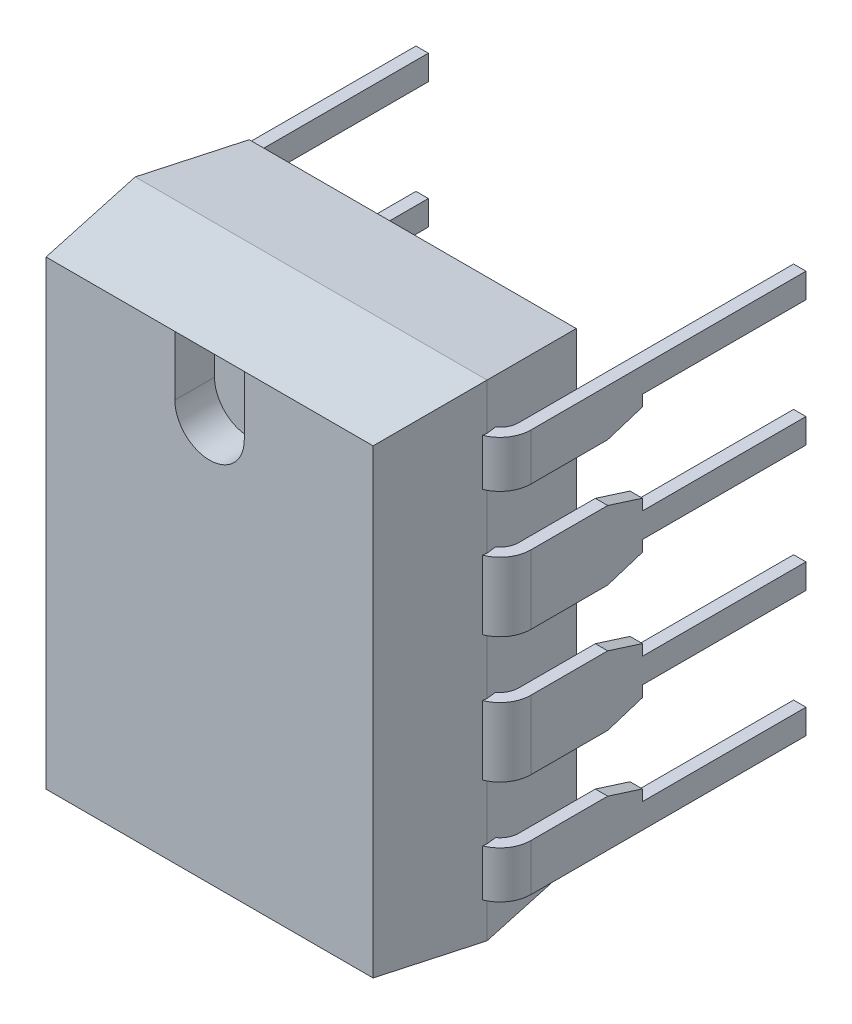
from build123d import *

# Parameters (mm, degrees)
BASIC_SHAPE_DEPTH              = 4.9
SIDE_PROFILE1_DEPTH            = 4.55
SIDE_PROFILE1_DEPTH_BACK       = 4.55
SIDE_PROFILE2_DEPTH            = 4.55
SIDE_PROFILE2_DEPTH_BACK       = 4.55
LOCATION_MARK_DEPTH            = 0.8
SKETCH6_W                      = 0.25
SKETCH6_H                      = 1.39
PIN_RELIEF_DEPTH               = 1.25
REMAINING_PINS_COUNT           = 4
REMAINING_PINS_PITCH           = 2.54
REMAINING_PINS_COPY_1_SKETCH_W = 0.25
REMAINING_PINS_COPY_1_SKETCH_H = 1.39
REMAINING_PINS_COPY_2_SKETCH_W = 0.25
REMAINING_PINS_COPY_2_SKETCH_H = 1.39
REMAINING_PINS_COPY_3_SKETCH_W = 0.25
REMAINING_PINS_COPY_3_SKETCH_H = 1.39
REMAINING_PINS_COPY_4_DEPTH    = 1.25
REMAINING_PINS_COPY_5_DEPTH    = 1.25
REMAINING_PINS_COPY_6_DEPTH    = 1.25
PIN_SHAPE1_DEPTH               = 0.445
PIN_START                      = -0.445
PIN_SHAPE2_DEPTH               = 0.445


with BuildPart() as part:
    # Sketch1 → Basic Shape (new body, symmetric)
    with BuildSketch(Plane(origin=(0, 0, 0), x_dir=(1, 0, 0), z_dir=(0, 1, 0))):
        Polygon((-3.3, -0.7), (-3.55, -2.75), (-3.3, -4.8), (3.3, -4.8), (3.55, -2.75), (3.3, -0.7), align=None)
    extrude(amount=BASIC_SHAPE_DEPTH, both=True)

    # Sketch2 → Side Profile1 (cut, two sides)
    with BuildSketch(Plane(origin=(0, 0, 0), x_dir=(0, 0, -1), z_dir=(1, 0, 0))) as side_profile1_sk:
        Polygon((-4.8, 4.9), (-4.8, 4.65), (-2.75, 4.9), align=None)
        Polygon((-4.8, -4.9), (-2.75, -4.9), (-4.8, -4.65), align=None)
    extrude(amount=SIDE_PROFILE1_DEPTH, mode=Mode.SUBTRACT)
    extrude(side_profile1_sk.sketch, amount=-SIDE_PROFILE1_DEPTH_BACK, mode=Mode.SUBTRACT)

    # Sketch3 → Side Profile2 (cut, two sides)
    with BuildSketch(Plane(origin=(0, 0, 0), x_dir=(0, 0, -1), z_dir=(1, 0, 0))) as side_profile2_sk:
        Polygon((-2.75, 4.9), (-0.7, 4.9), (-0.7, 4.65), align=None)
        Polygon((-2.75, -4.9), (-0.7, -4.9), (-0.7, -4.65), align=None)
    extrude(amount=SIDE_PROFILE2_DEPTH, mode=Mode.SUBTRACT)
    extrude(side_profile2_sk.sketch, amount=-SIDE_PROFILE2_DEPTH_BACK, mode=Mode.SUBTRACT)

    # Sketch4 → Location Mark (cut)
    with BuildSketch(Plane(origin=(0, 0, 4.8), x_dir=(-1, 0, 0), z_dir=(0, 0, -1))):
        with BuildLine():
            Line((0.7, 4.65), (0.7, 3.45))
            ThreePointArc((0.7, 3.45), (0, 2.75), (-0.7, 3.45))
            Line((-0.7, 3.45), (-0.7, 4.65))
            Line((-0.7, 4.65), (0.7, 4.65))
        make_face()
    extrude(amount=LOCATION_MARK_DEPTH, mode=Mode.SUBTRACT)

    # First Pin: sweep along a path in Sketch5
    with BuildLine(Plane(origin=(0, -3.9, 0), x_dir=(1, 0, 0), z_dir=(0, 1, 0))) as first_pin_path:
        Line((0, -2.75), (3.31, -2.75))
        ThreePointArc((3.31, -2.75), (3.663553391, -2.603553391), (3.81, -2.25))
        Line((3.81, -2.25), (3.81, 3.3))
    # Sketch6 → First Pin (sweep)
    with BuildSketch(Plane(origin=(0, 0, 0), x_dir=(0, 0, -1), z_dir=(1, 0, 0))):
        with Locations((-2.75, -3.9)):
            Rectangle(SKETCH6_W, SKETCH6_H)
    first_pin = sweep(path=first_pin_path.line)

    # Sketch7 → Pin Relief (cut, through all)
    with BuildSketch(Plane.ZY.offset(-3.685)):
        Polygon((-3.3, -4.15), (0, -4.15), (0, -4.3725), (0.7, -4.595), (-3.3, -4.595), align=None)
        Polygon((-3.3, -3.65), (0, -3.65), (0, -3.4275), (0.7, -3.205), (-3.3, -3.205), align=None)
    pin_relief = extrude(amount=-PIN_RELIEF_DEPTH, mode=Mode.SUBTRACT)

    # Opp Pin: First Pin, Pin Relief across plane
    add(first_pin.mirror(Plane(origin=(0, 0, 0), x_dir=(0, 0, 1), z_dir=(1, 0, 0))))
    add(pin_relief.mirror(Plane(origin=(0, 0, 0), x_dir=(0, 0, 1), z_dir=(1, 0, 0))), mode=Mode.SUBTRACT)

    # Remaining Pins: First Pin, Pin Relief ×4
    with Locations(*[(0, i * REMAINING_PINS_PITCH, 0) for i in range(1, REMAINING_PINS_COUNT)]):
        add(first_pin)
        add(pin_relief, mode=Mode.SUBTRACT)

    # Remaining Pins copy 1: sweep along a path in Remaining Pins copy 1 path
    with BuildLine(Plane(origin=(0, -1.36, 0), x_dir=(-1, 0, 0), z_dir=(0, 1, 0))) as remaining_pins_copy_1_path:
        Line((0, 2.75), (3.31, 2.75))
        ThreePointArc((3.31, 2.75), (3.663553391, 2.603553391), (3.81, 2.25))
        Line((3.81, 2.25), (3.81, -3.3))
    # Remaining Pins copy 1 sketch → Remaining Pins copy 1 (sweep)
    with BuildSketch(Plane(origin=(0, 2.54, 0), x_dir=(0, 0, -1), z_dir=(-1, 0, 0))):
        with Locations((-2.75, 3.9)):
            Rectangle(REMAINING_PINS_COPY_1_SKETCH_W, REMAINING_PINS_COPY_1_SKETCH_H)
    sweep(path=remaining_pins_copy_1_path.line)

    # Remaining Pins copy 2: sweep along a path in Remaining Pins copy 2 path
    with BuildLine(Plane(origin=(0, 1.18, 0), x_dir=(-1, 0, 0), z_dir=(0, 1, 0))) as remaining_pins_copy_2_path:
        Line((0, 2.75), (3.31, 2.75))
        ThreePointArc((3.31, 2.75), (3.663553391, 2.603553391), (3.81, 2.25))
        Line((3.81, 2.25), (3.81, -3.3))
    # Remaining Pins copy 2 sketch → Remaining Pins copy 2 (sweep)
    with BuildSketch(Plane(origin=(0, 5.08, 0), x_dir=(0, 0, -1), z_dir=(-1, 0, 0))):
        with Locations((-2.75, 3.9)):
            Rectangle(REMAINING_PINS_COPY_2_SKETCH_W, REMAINING_PINS_COPY_2_SKETCH_H)
    sweep(path=remaining_pins_copy_2_path.line)

    # Remaining Pins copy 3: sweep along a path in Remaining Pins copy 3 path
    with BuildLine(Plane(origin=(0, 3.72, 0), x_dir=(-1, 0, 0), z_dir=(0, 1, 0))) as remaining_pins_copy_3_path:
        Line((0, 2.75), (3.31, 2.75))
        ThreePointArc((3.31, 2.75), (3.663553391, 2.603553391), (3.81, 2.25))
        Line((3.81, 2.25), (3.81, -3.3))
    # Remaining Pins copy 3 sketch → Remaining Pins copy 3 (sweep)
    with BuildSketch(Plane(origin=(0, 7.62, 0), x_dir=(0, 0, -1), z_dir=(-1, 0, 0))):
        with Locations((-2.75, 3.9)):
            Rectangle(REMAINING_PINS_COPY_3_SKETCH_W, REMAINING_PINS_COPY_3_SKETCH_H)
    sweep(path=remaining_pins_copy_3_path.line)

    # Remaining Pins copy 4 sketch → Remaining Pins copy 4 (cut, through all)
    with BuildSketch(Plane(origin=(-3.685, 2.54, 0), x_dir=(0, 0, 1), z_dir=(1, 0, 0))):
        Polygon((-3.3, 4.15), (0, 4.15), (0, 4.3725), (0.7, 4.595), (-3.3, 4.595), align=None)
        Polygon((-3.3, 3.65), (0, 3.65), (0, 3.4275), (0.7, 3.205), (-3.3, 3.205), align=None)
    extrude(amount=-REMAINING_PINS_COPY_4_DEPTH, mode=Mode.SUBTRACT)

    # Remaining Pins copy 5 sketch → Remaining Pins copy 5 (cut, through all)
    with BuildSketch(Plane(origin=(-3.685, 5.08, 0), x_dir=(0, 0, 1), z_dir=(1, 0, 0))):
        Polygon((-3.3, 4.15), (0, 4.15), (0, 4.3725), (0.7, 4.595), (-3.3, 4.595), align=None)
        Polygon((-3.3, 3.65), (0, 3.65), (0, 3.4275), (0.7, 3.205), (-3.3, 3.205), align=None)
    extrude(amount=-REMAINING_PINS_COPY_5_DEPTH, mode=Mode.SUBTRACT)

    # Remaining Pins copy 6 sketch → Remaining Pins copy 6 (cut, through all)
    with BuildSketch(Plane(origin=(-3.685, 7.62, 0), x_dir=(0, 0, 1), z_dir=(1, 0, 0))):
        Polygon((-3.3, 4.15), (0, 4.15), (0, 4.3725), (0.7, 4.595), (-3.3, 4.595), align=None)
        Polygon((-3.3, 3.65), (0, 3.65), (0, 3.4275), (0.7, 3.205), (-3.3, 3.205), align=None)
    extrude(amount=-REMAINING_PINS_COPY_6_DEPTH, mode=Mode.SUBTRACT)

    # Sketch9 → Pin Shape1 (cut)
    with BuildSketch(Plane.XZ.offset(4.595)):
        with BuildLine():
            Line((3.935, 0), (3.685, 0))
            Line((3.685, 0), (3.685, 2.25))
            ThreePointArc((3.685, 2.25), (3.642990838, 2.422458987), (3.526375455, 2.556278733))
            Line((3.526375455, 2.556278733), (3.55, 2.75))
            Line((3.55, 2.75), (3.540110055, 2.83109755))
            ThreePointArc((3.540110055, 2.83109755), (3.826935095, 2.601287785), (3.935, 2.25))
            Line((3.935, 2.25), (3.935, 0))
        make_face()
        with BuildLine():
            Line((-3.935, 0), (-3.685, 0))
            Line((-3.685, 0), (-3.685, 2.25))
            ThreePointArc((-3.685, 2.25), (-3.642990838, 2.422458987), (-3.526375455, 2.556278733))
            Line((-3.526375455, 2.556278733), (-3.55, 2.75))
            Line((-3.55, 2.75), (-3.540110055, 2.83109755))
            ThreePointArc((-3.540110055, 2.83109755), (-3.826935095, 2.601287785), (-3.935, 2.25))
            Line((-3.935, 2.25), (-3.935, 0))
        make_face()
    extrude(amount=-PIN_SHAPE1_DEPTH, mode=Mode.SUBTRACT)

    # Sketch10 → Pin Shape2 (cut)
    with BuildSketch(Plane(origin=(0, 4.415, 0), x_dir=(-1, 0, 0), z_dir=(0, 1, 0)).offset(PIN_START)):
        with BuildLine():
            Line((-3.935, 0), (-3.685, 0))
            Line((-3.685, 0), (-3.685, 2.25))
            ThreePointArc((-3.685, 2.25), (-3.642990838, 2.422458987), (-3.526375455, 2.556278733))
            Line((-3.526375455, 2.556278733), (-3.55, 2.75))
            Line((-3.55, 2.75), (-3.540110055, 2.83109755))
            ThreePointArc((-3.540110055, 2.83109755), (-3.826935095, 2.601287785), (-3.935, 2.25))
            Line((-3.935, 2.25), (-3.935, 0))
        make_face()
        with BuildLine():
            Line((3.935, 0), (3.685, 0))
            Line((3.685, 0), (3.685, 2.25))
            ThreePointArc((3.685, 2.25), (3.642990838, 2.422458987), (3.526375455, 2.556278733))
            Line((3.526375455, 2.556278733), (3.55, 2.75))
            Line((3.55, 2.75), (3.540110055, 2.83109755))
            ThreePointArc((3.540110055, 2.83109755), (3.826935095, 2.601287785), (3.935, 2.25))
            Line((3.935, 2.25), (3.935, 0))
        make_face()
    extrude(amount=PIN_SHAPE2_DEPTH, mode=Mode.SUBTRACT)


solid = part.part
